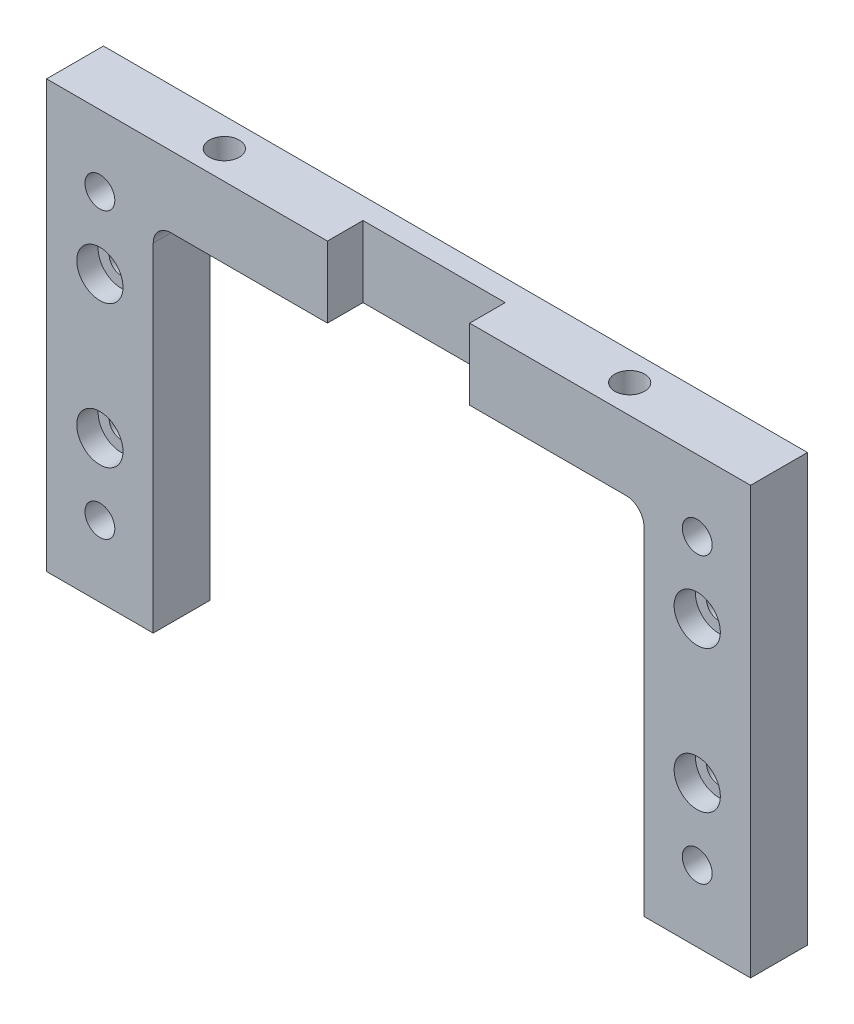
from build123d import *

# Parameters (mm, degrees)
BOSS_EXTRUDE1_DEPTH            = 4
CBORE_FOR_M3_SHCS2_D           = 3.4
CBORE_FOR_M3_SHCS2_CBORE_D     = 6.5
CBORE_FOR_M3_SHCS2_CBORE_DEPTH = 3
M5X0_8_TAPPED_HOLE1_D          = 4.2
M5X0_8_TAPPED_HOLE2_D          = 4.2
SKETCH8_W                      = 20
SKETCH8_H                      = 10
CUT_EXTRUDE1_DEPTH             = 5


with BuildPart() as part:
    # Sketch1 → Boss-Extrude1 (new body, symmetric)
    with BuildSketch(Plane.XY):
        with BuildLine():
            Line((-34.5, 0), (-49.5, 0))
            Line((-49.5, 0), (-49.5, 60))
            Line((-49.5, 60), (49.5, 60))
            Line((49.5, 60), (49.5, 0))
            Line((49.5, 0), (34.5, 0))
            Line((34.5, 0), (34.5, 47.5))
            ThreePointArc((34.5, 47.5), (33.767766953, 49.267766953), (32, 50))
            Line((32, 50), (-32, 50))
            ThreePointArc((-32, 50), (-33.767766953, 49.267766953), (-34.5, 47.5))
            Line((-34.5, 47.5), (-34.5, 0))
        make_face()
    extrude(amount=BOSS_EXTRUDE1_DEPTH, both=True)

    # CBORE for M3 SHCS2 (through all)
    with Locations(Plane.XY.offset(4)):
        with Locations((-42, 40), (-42, 20)):
            cbore_for_m3_shcs2 = CounterBoreHole(CBORE_FOR_M3_SHCS2_D / 2, CBORE_FOR_M3_SHCS2_CBORE_D / 2, CBORE_FOR_M3_SHCS2_CBORE_DEPTH)

    # M5x0.8 Tapped Hole1 (through all)
    with Locations(Plane.XY.offset(4)):
        with Locations((-42, 10), (-42, 50)):
            m5x0_8_tapped_hole1 = Hole(M5X0_8_TAPPED_HOLE1_D / 2)

    # M5x0.8 Tapped Hole2 (through all)
    with Locations(Plane(origin=(0, 60, 0), x_dir=(1, 0, 0), z_dir=(0, 1, 0))):
        with Locations((-28.5, 0)):
            m5x0_8_tapped_hole2 = Hole(M5X0_8_TAPPED_HOLE2_D / 2)

    # Mirror1: CBORE for M3 SHCS2, M5x0.8 Tapped Hole1, M5x0.8 Tapped Hole2 across plane
    add(cbore_for_m3_shcs2.mirror(Plane(origin=(0, 0, 0), x_dir=(0, 0, 1), z_dir=(1, 0, 0))), mode=Mode.SUBTRACT)
    add(m5x0_8_tapped_hole1.mirror(Plane(origin=(0, 0, 0), x_dir=(0, 0, 1), z_dir=(1, 0, 0))), mode=Mode.SUBTRACT)
    add(m5x0_8_tapped_hole2.mirror(Plane(origin=(0, 0, 0), x_dir=(0, 0, 1), z_dir=(1, 0, 0))), mode=Mode.SUBTRACT)

    # Sketch8 → Cut-Extrude1 (cut)
    with BuildSketch(Plane.XY.offset(4)):
        with Locations((0, 55)):
            Rectangle(SKETCH8_W, SKETCH8_H)
    extrude(amount=-CUT_EXTRUDE1_DEPTH, mode=Mode.SUBTRACT)


solid = part.part
